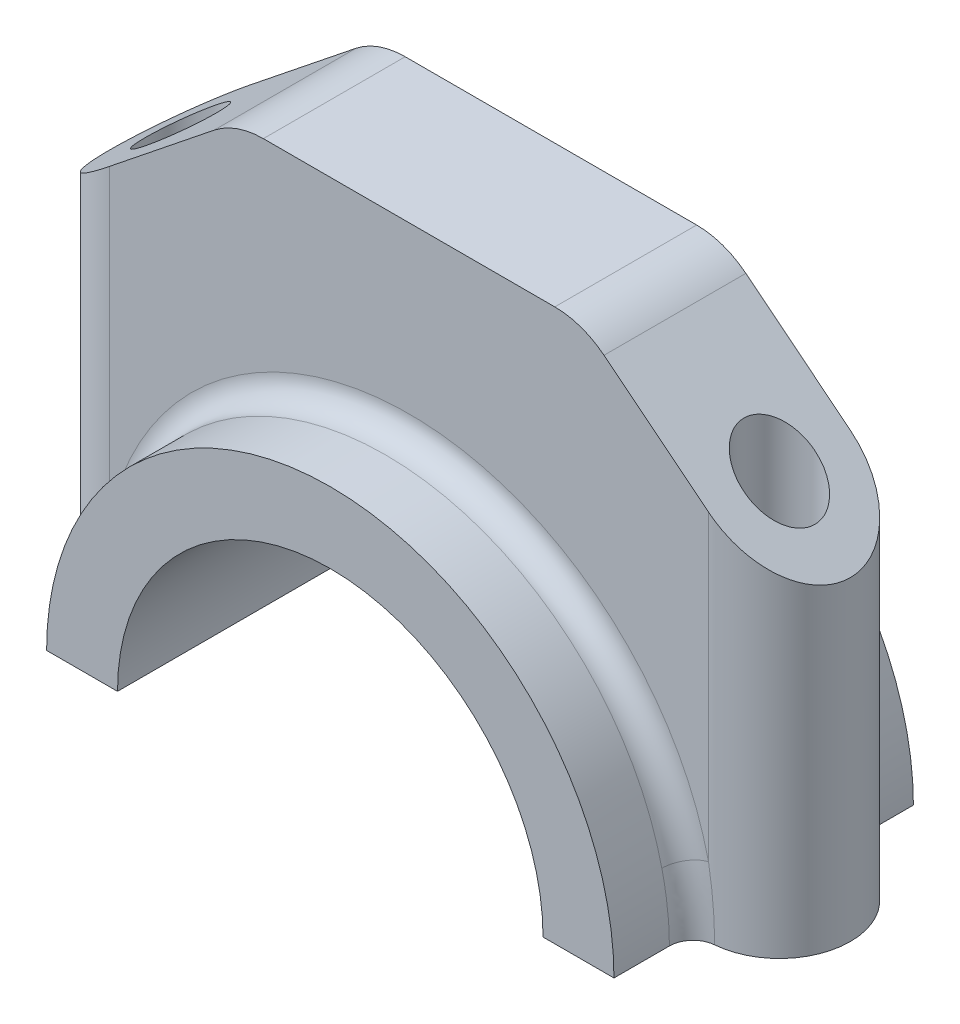
from build123d import *

# Parameters (mm, degrees)
BOSS_EXTRUDE1_DEPTH     = 19
BOSS_EXTRUDE2_DEPTH     = 60
CUT_EXTRUDE1_DEPTH      = 29
SKETCH4_R               = 4.5
CUT_EXTRUDE2_DEPTH      = 61
CUT_EXTRUDE4_DEPTH      = 20
CUT_EXTRUDE4_DEPTH_BACK = 20
FILLET1_R               = 10
FILLET2_R               = 3


with BuildPart() as part:
    # Sketch1 → Boss-Extrude1 (new body, symmetric)
    with BuildSketch(Plane.XY):
        with BuildLine():
            Line((-36, 0), (-27, 0))
            ThreePointArc((-27, 0), (0, 27), (27, 0))
            Line((27, 0), (36, 0))
            ThreePointArc((36, 0), (0, 36), (-36, 0))
        make_face()
    extrude(amount=BOSS_EXTRUDE1_DEPTH, both=True)

    # Sketch2 → Boss-Extrude2 (add)
    with BuildSketch(Plane(origin=(0, 60, 0), x_dir=(-1, 0, 0), z_dir=(0, -1, 0))):
        with BuildLine():
            Line((38, -9), (-38, -9))
            ThreePointArc((-38, -9), (-47, 0), (-38, 9))
            Line((-38, 9), (38, 9))
            ThreePointArc((38, 9), (47, 0), (38, -9))
        make_face()
    extrude(amount=BOSS_EXTRUDE2_DEPTH)

    # Sketch3 → Cut-Extrude1 (cut, through all)
    with BuildSketch(Plane.XY.offset(9)):
        with BuildLine():
            Line((-27, 0), (27, 0))
            ThreePointArc((27, 0), (0, 27), (-27, 0))
        make_face()
    extrude(amount=-CUT_EXTRUDE1_DEPTH, mode=Mode.SUBTRACT)

    # Sketch4 → Cut-Extrude2 (cut, through all)
    with BuildSketch(Plane.XZ):
        with Locations((-38, 0)):
            Circle(SKETCH4_R)
        with Locations((38, 0)):
            Circle(SKETCH4_R)
    extrude(amount=-CUT_EXTRUDE2_DEPTH, mode=Mode.SUBTRACT)

    # Sketch5 → Cut-Extrude4 (cut, two sides)
    with BuildSketch(Plane.XY) as cut_extrude4_sk:
        Polygon((-47, 40), (-22, 60), (-47, 60), align=None)
        Polygon((47, 60), (47, 40), (22, 60), align=None)
    extrude(amount=CUT_EXTRUDE4_DEPTH, mode=Mode.SUBTRACT)
    extrude(cut_extrude4_sk.sketch, amount=-CUT_EXTRUDE4_DEPTH_BACK, mode=Mode.SUBTRACT)

    # Fillet1
    fillet1_edges = [part.edges().sort_by_distance(p)[0] for p in [
        (-22, 60, 0),
        (22, 60, 0),
    ]]
    fillet(fillet1_edges, radius=FILLET1_R)

    # Fillet2
    fillet2_edges = [part.edges().sort_by_distance(p)[0] for p in [
        (0, 36, 9),
        (0, 36, -9),
    ]]
    fillet(fillet2_edges, radius=FILLET2_R)


solid = part.part
